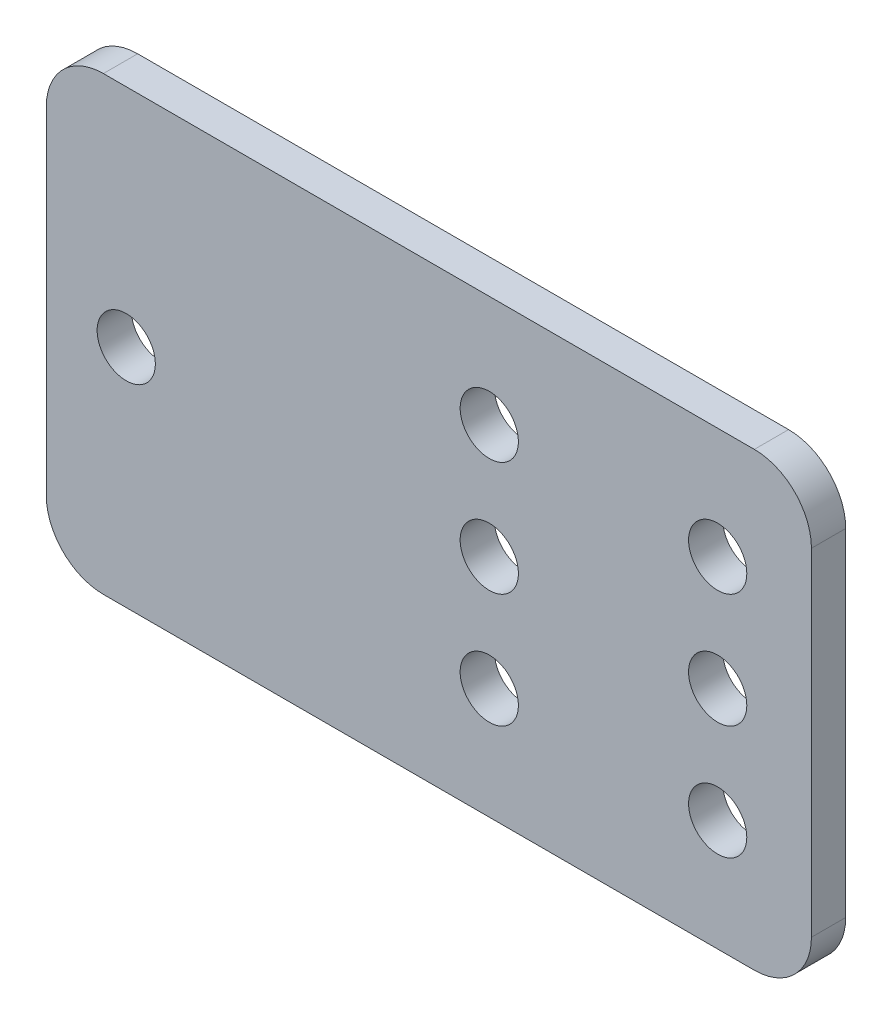
from build123d import *

# Parameters (mm, degrees)
SKETCH1_R           = 2.55
BOSS_EXTRUDE1_DEPTH = 1.5


with BuildPart() as part:
    # Sketch1 → Boss-Extrude1 (new body, symmetric)
    with BuildSketch(Plane.XY):
        with BuildLine():
            Line((-28.5, -19.75), (28.5, -19.75))
            ThreePointArc((28.5, -19.75), (32.035533906, -18.285533906), (33.5, -14.75))
            Line((33.5, -14.75), (33.5, 14.75))
            ThreePointArc((33.5, 14.75), (32.035533906, 18.285533906), (28.5, 19.75))
            Line((28.5, 19.75), (-28.5, 19.75))
            ThreePointArc((-28.5, 19.75), (-32.035533906, 18.285533906), (-33.5, 14.75))
            Line((-33.5, 14.75), (-33.5, -14.75))
            ThreePointArc((-33.5, -14.75), (-32.035533906, -18.285533906), (-28.5, -19.75))
        make_face()
        with Locations((5.29, 10)):
            Circle(SKETCH1_R, mode=Mode.SUBTRACT)
        with Locations((25.29, 10)):
            Circle(SKETCH1_R, mode=Mode.SUBTRACT)
        with Locations((5.29, 0)):
            Circle(SKETCH1_R, mode=Mode.SUBTRACT)
        with Locations((25.29, 0)):
            Circle(SKETCH1_R, mode=Mode.SUBTRACT)
        with Locations((5.29, -10)):
            Circle(SKETCH1_R, mode=Mode.SUBTRACT)
        with Locations((25.29, -10)):
            Circle(SKETCH1_R, mode=Mode.SUBTRACT)
        with Locations((-26.5, 0)):
            Circle(SKETCH1_R, mode=Mode.SUBTRACT)
    extrude(amount=BOSS_EXTRUDE1_DEPTH, both=True)


solid = part.part
